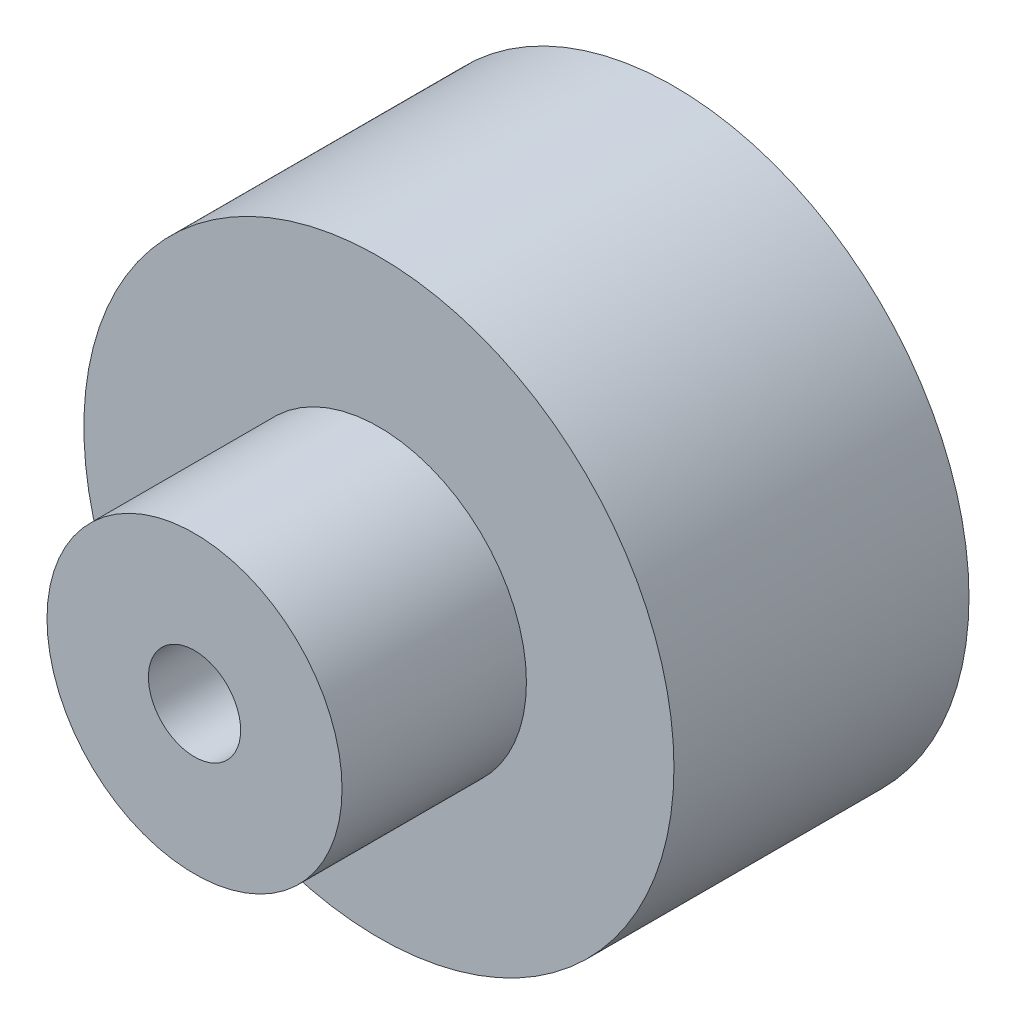
from build123d import *

# Parameters (mm, degrees)
SKETCH1_R             = 8
BOSS_EXTRUDE1_DEPTH   = 8
SKETCH2_R             = 4
BOSS_EXTRUDE2_DEPTH   = 5
M3_TAPPED_HOLE1_D     = 2.5
M3_TAPPED_HOLE1_DEPTH = 8.5
M3_TAPPED_HOLE1_TIP   = 0.751075774


with BuildPart() as part:
    # Sketch1 → Boss-Extrude1 (new body)
    with BuildSketch(Plane.XY):
        Circle(SKETCH1_R)
    extrude(amount=BOSS_EXTRUDE1_DEPTH)

    # Sketch2 → Boss-Extrude2 (add)
    with BuildSketch(Plane.XY.offset(8)):
        Circle(SKETCH2_R)
    extrude(amount=BOSS_EXTRUDE2_DEPTH)

    # M3 Tapped Hole1
    with Locations(Plane.XY.offset(13)):
        with Locations((0, 0)):
            Hole(M3_TAPPED_HOLE1_D / 2, depth=M3_TAPPED_HOLE1_DEPTH)
            with Locations((0, 0, -(M3_TAPPED_HOLE1_DEPTH + M3_TAPPED_HOLE1_TIP / 2))):  # 118° drill point
                Cone(0, M3_TAPPED_HOLE1_D / 2, M3_TAPPED_HOLE1_TIP, mode=Mode.SUBTRACT)


solid = part.part
